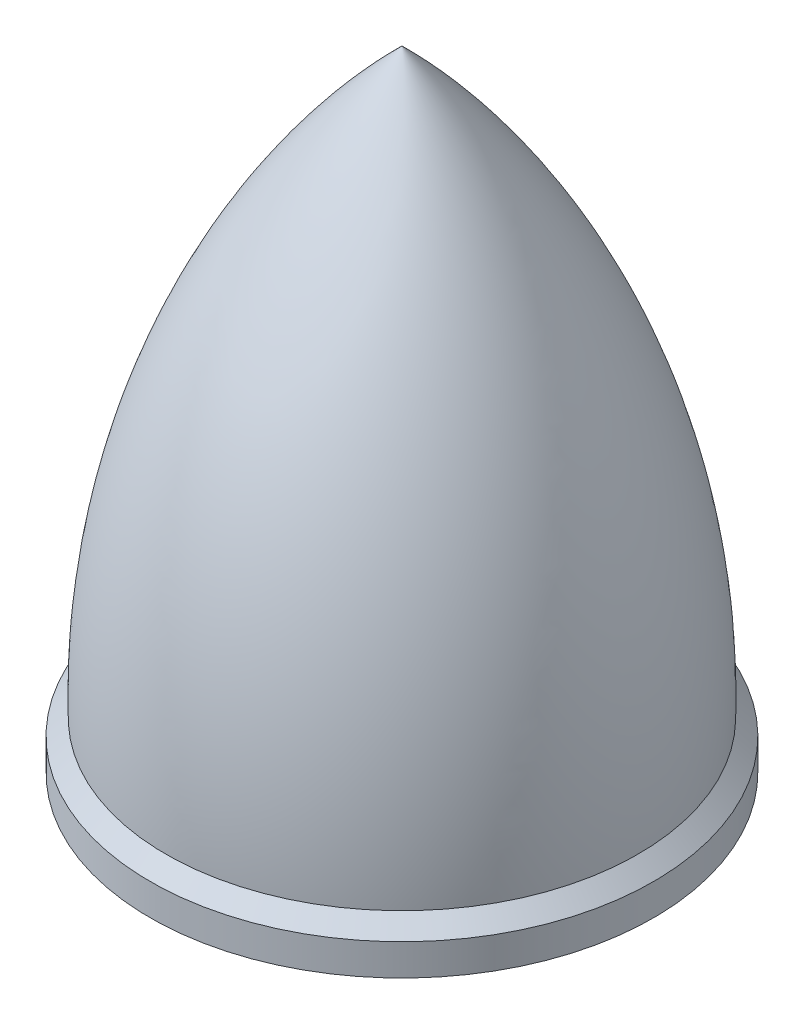
from build123d import *

# Parameters (mm, degrees)
F_5_0_5_DIAMETER_HOLE1_D     = 5
F_5_0_5_DIAMETER_HOLE1_DEPTH = 10
F_5_0_5_DIAMETER_HOLE1_TIP   = 1.502151548


with BuildPart() as part:
    # Sketch2 → Revolve1 (revolve)
    with BuildSketch(Plane.XY):
        with BuildLine():
            Line((0, 0), (8, 0))
            Line((8, 0), (8, 1))
            Line((8, 1), (7.5, 1.5))
            ThreePointArc((7.5, 1.5), (5.676635163, 11.531068309), (0, 20))
            Line((0, 20), (0, 0))
        make_face()
    revolve(axis=Axis((0, 0, 0), (0, 1, 0)))

    # Ø5.0 (5) Diameter Hole1
    with Locations(Plane(origin=(0, 0, 0), x_dir=(-1, 0, 0), z_dir=(0, -1, 0))):
        with Locations((0, 0)):
            Hole(F_5_0_5_DIAMETER_HOLE1_D / 2, depth=F_5_0_5_DIAMETER_HOLE1_DEPTH)
            with Locations((0, 0, -(F_5_0_5_DIAMETER_HOLE1_DEPTH + F_5_0_5_DIAMETER_HOLE1_TIP / 2))):  # 118° drill point
                Cone(0, F_5_0_5_DIAMETER_HOLE1_D / 2, F_5_0_5_DIAMETER_HOLE1_TIP, mode=Mode.SUBTRACT)


solid = part.part
